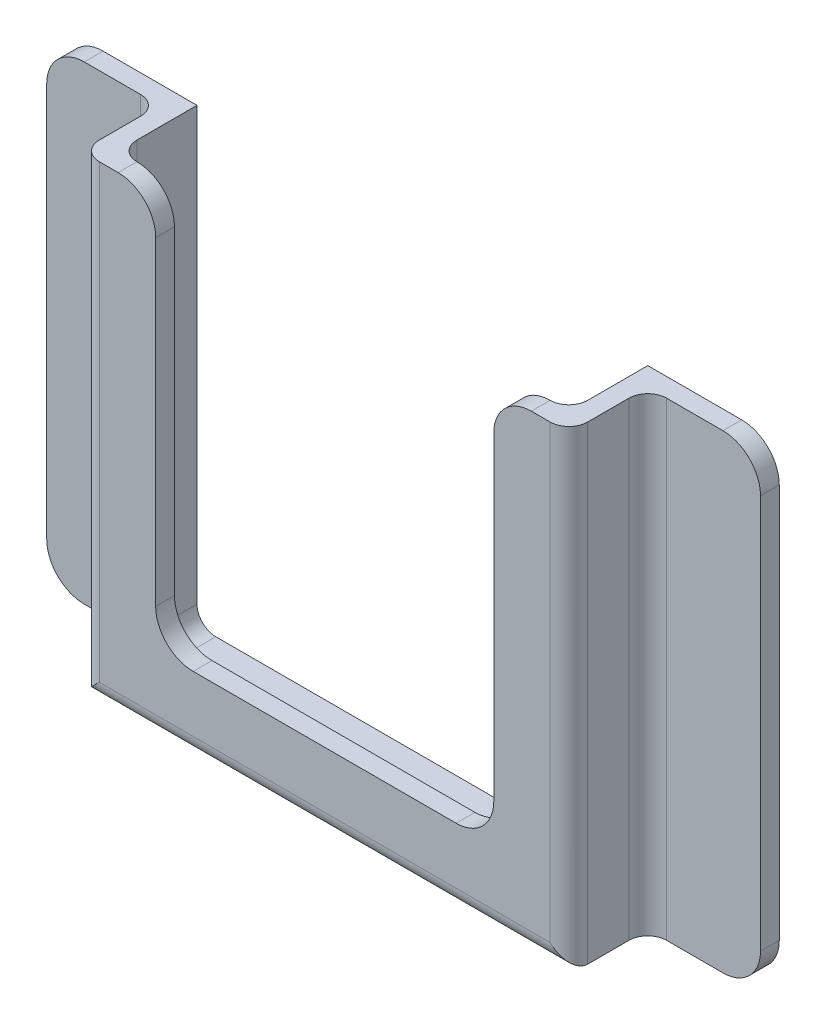
from build123d import *

# Parameters (mm, degrees)
BOSS_EXTRUDE1_DEPTH = 10.5
BOSS_EXTRUDE2_DEPTH = 2.5
SKETCH3_W           = 15
SKETCH3_H           = 62.5
BOSS_EXTRUDE3_DEPTH = 2.5
FILLET1_R           = 2.5
FILLET2_R           = 5


with BuildPart() as part:
    # Sketch1 → Boss-Extrude1 (new body)
    with BuildSketch(Plane.XY):
        Polygon((60, 60), (62.5, 60), (62.5, -2.5), (-2.5, -2.5), (-2.5, 60), (0, 60), (0, 0), (60, 0), align=None)
    extrude(amount=BOSS_EXTRUDE1_DEPTH)

    # Sketch2 → Boss-Extrude2 (add)
    with BuildSketch(Plane.XY.offset(10.5)):
        Polygon((52.5, 60), (62.5, 60), (62.5, -2.5), (-2.5, -2.5), (-2.5, 60), (7.5, 60), (7.5, 7.5), (52.5, 7.5), align=None)
    extrude(amount=BOSS_EXTRUDE2_DEPTH)

    # Sketch3 → Boss-Extrude3 (add)
    with BuildSketch(Plane(origin=(0, 0, 0), x_dir=(-1, 0, 0), z_dir=(0, 0, -1))):
        with Locations((-70, 28.75)):
            Rectangle(SKETCH3_W, SKETCH3_H)
        with Locations((10, 28.75)):
            Rectangle(SKETCH3_W, SKETCH3_H)
    extrude(amount=-BOSS_EXTRUDE3_DEPTH)

    # Fillet1
    fillet1_edges = [part.edges().sort_by_distance(p)[0] for p in [
        (0, 0, 5.25),
        (60, 0, 5.25),
        (60, 30, 10.5),
        (-2.5, 28.75, 13),
        (30, -2.5, 13),
        (62.5, 28.75, 13),
        (0, 30, 10.5),
        (62.5, 28.75, 2.5),
        (-2.5, 28.75, 2.5),
    ]]
    fillet(fillet1_edges, radius=FILLET1_R)

    # Fillet2
    fillet2_edges = [part.edges().sort_by_distance(p)[0] for p in [
        (7.5, 7.5, 11.75),
        (52.5, 7.5, 11.75),
        (-17.5, 60, 1.25),
        (-17.5, -2.5, 1.25),
        (77.5, -2.5, 1.25),
        (77.5, 60, 1.25),
        (52.5, 60, 11.75),
        (7.5, 60, 11.75),
    ]]
    fillet(fillet2_edges, radius=FILLET2_R)


solid = part.part
